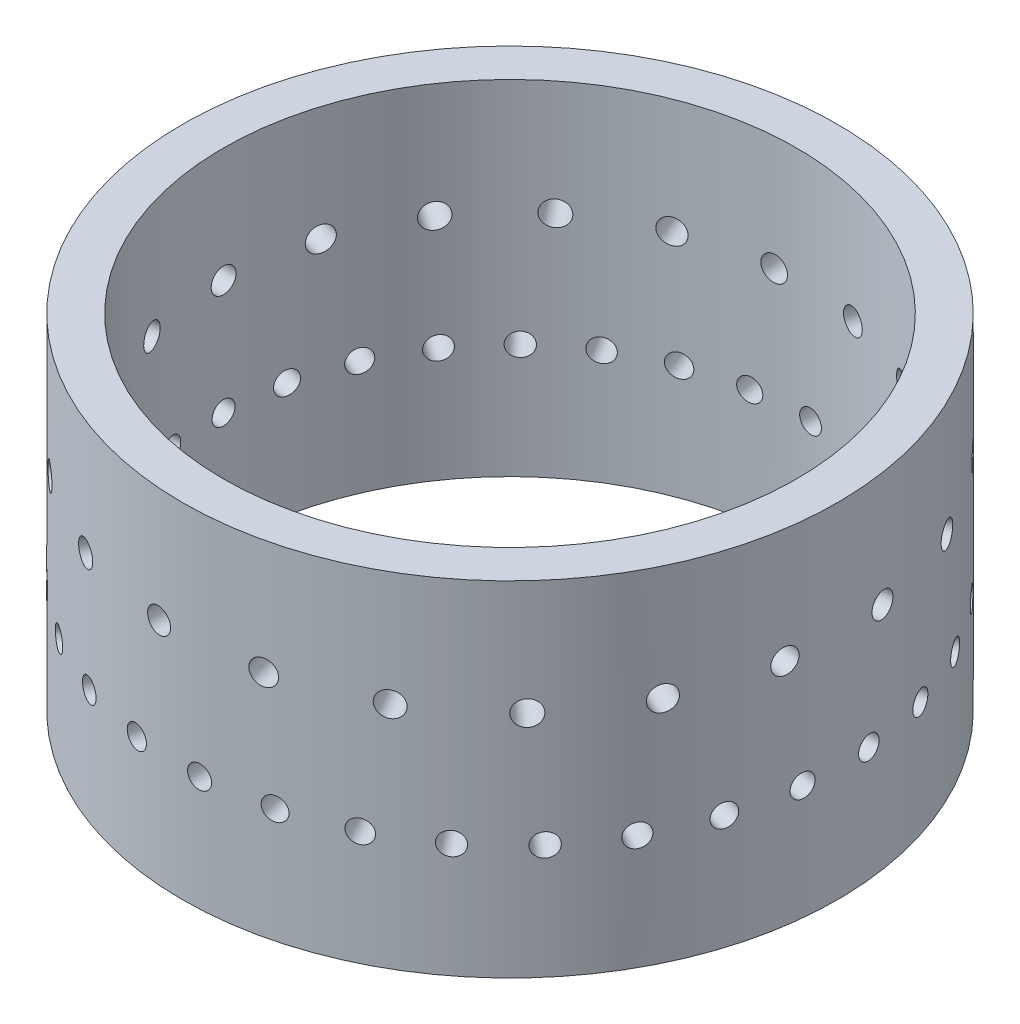
from build123d import *

# Parameters (mm, degrees)
SKETCH1_R           = 25.4
SKETCH1_R_2         = 22.225
BOSS_EXTRUDE1_DEPTH = 26.67
SKETCH2_R           = 0.889
CUT_EXTRUDE1_DEPTH  = 26.67
CIRPATTERN1_COUNT   = 31
SKETCH4_R           = 0.9652
CUT_EXTRUDE2_DEPTH  = 26.67
CIRPATTERN2_COUNT   = 21


with BuildPart() as part:
    # Sketch1 → Boss-Extrude1 (new body)
    with BuildSketch(Plane(origin=(0, 0, 0), x_dir=(1, 0, 0), z_dir=(0, 1, 0))):
        Circle(SKETCH1_R)
        Circle(SKETCH1_R_2, mode=Mode.SUBTRACT)
    extrude(amount=BOSS_EXTRUDE1_DEPTH)

    # Sketch2 → Cut-Extrude1 (cut)
    with BuildSketch(Plane(origin=(0, 0, 0), x_dir=(0, 0, -1), z_dir=(1, 0, 0))):
        with Locations((0, 8.89)):
            Circle(SKETCH2_R)
    cut_extrude1 = extrude(amount=-CUT_EXTRUDE1_DEPTH, mode=Mode.SUBTRACT)

    # CirPattern1: Cut-Extrude1 ×31 about axis
    cirpattern1_axis = Axis((0, 0, 0), (0, 1, 0))
    for i in range(1, CIRPATTERN1_COUNT):
        add(cut_extrude1.rotate(cirpattern1_axis, i * 360 / CIRPATTERN1_COUNT), mode=Mode.SUBTRACT)

    # Sketch4 → Cut-Extrude2 (cut)
    with BuildSketch(Plane(origin=(0, 0, 0), x_dir=(0, 0, -1), z_dir=(1, 0, 0))):
        with Locations((0, 17.78)):
            Circle(SKETCH4_R)
    cut_extrude2 = extrude(amount=-CUT_EXTRUDE2_DEPTH, mode=Mode.SUBTRACT)

    # CirPattern2: Cut-Extrude2 ×21 about axis
    cirpattern2_axis = Axis((0, 0, 0), (0, 1, 0))
    for i in range(1, CIRPATTERN2_COUNT):
        add(cut_extrude2.rotate(cirpattern2_axis, i * 360 / CIRPATTERN2_COUNT), mode=Mode.SUBTRACT)


solid = part.part
